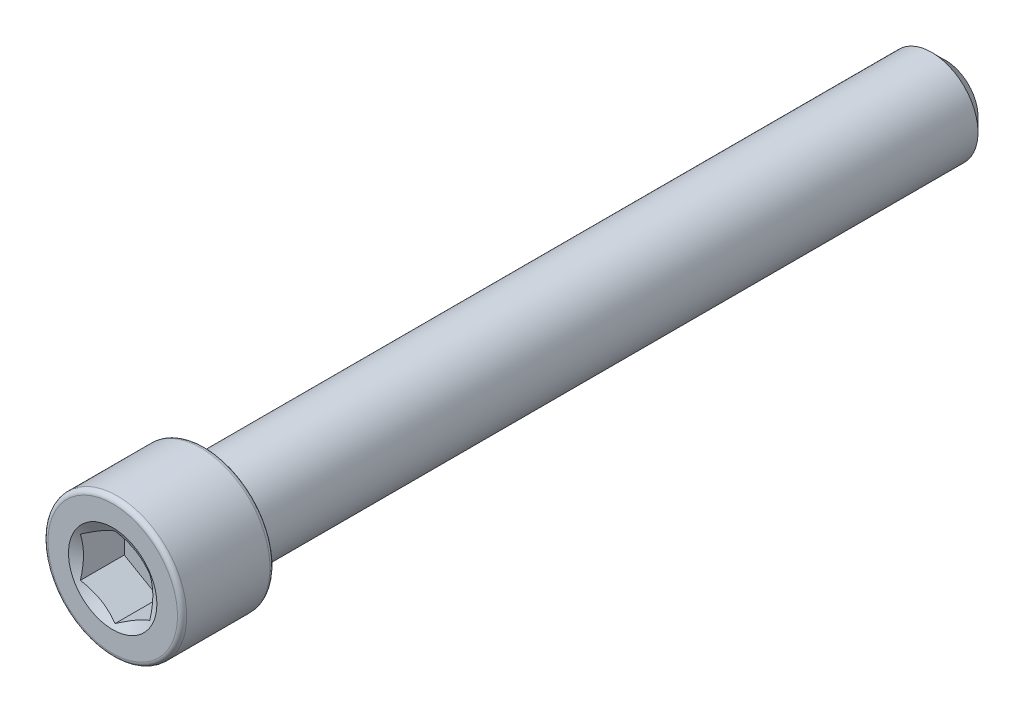
from build123d import *

# Parameters (mm, degrees)
CUT_EXTRUDE1_START = 28.575
CUT_EXTRUDE1_DEPTH = 3.175


with BuildPart() as part:
    # Sketch2 → Revolve1 (revolve)
    with BuildSketch(Plane(origin=(0, 0, 0), x_dir=(0, 0, -1), z_dir=(1, 0, 0)), mode=Mode.PRIVATE) as revolve1_sk:
        with BuildLine():
            Line((28.575, 0), (28.575, 2.2225))
            Line((28.575, 2.2225), (27.6225, 3.175))
            Line((27.6225, 3.175), (-22.225, 3.175))
            Line((-22.225, 3.175), (-22.225, 4.445))
            ThreePointArc((-22.225, 4.445), (-22.317993597, 4.669506403), (-22.5425, 4.7625))
            Line((-22.5425, 4.7625), (-28.2575, 4.7625))
            ThreePointArc((-28.2575, 4.7625), (-28.482006403, 4.669506403), (-28.575, 4.445))
            Line((-28.575, 4.445), (-28.575, 0))
            Line((-28.575, 0), (28.575, 0))
        make_face()
    revolve(revolve1_sk.sketch.rotate(Axis((0, 0, -28.575), (0, 0, 1)), 90), axis=Axis((0, 0, -28.575), (0, 0, 1)))

    # Sketch3 → Cut-Extrude1 (cut)
    with BuildSketch(Plane.XY.offset(CUT_EXTRUDE1_START)):
        Polygon((-2.38125, 1.374815329), (-2.38125, -1.374815329), (0, -2.749630657), (2.38125, -1.374815329), (2.38125, 1.374815329), (0, 2.749630657), align=None)
    extrude(amount=-CUT_EXTRUDE1_DEPTH, mode=Mode.SUBTRACT)

    # Cut-Extrude2 cone 1 section (through the dimple's axis) → Cut-Extrude2 (revolve, cut)
    with BuildSketch(Plane(origin=(0, 0, 28.575), x_dir=(0, -1, 0), z_dir=(1, 0, 0))):
        Polygon((0, 0), (3.032192214, 0), (0, 1.750636991), align=None)
    revolve(axis=Axis((0, 0, 28.575), (0, 0, -1)), mode=Mode.SUBTRACT)


solid = part.part
